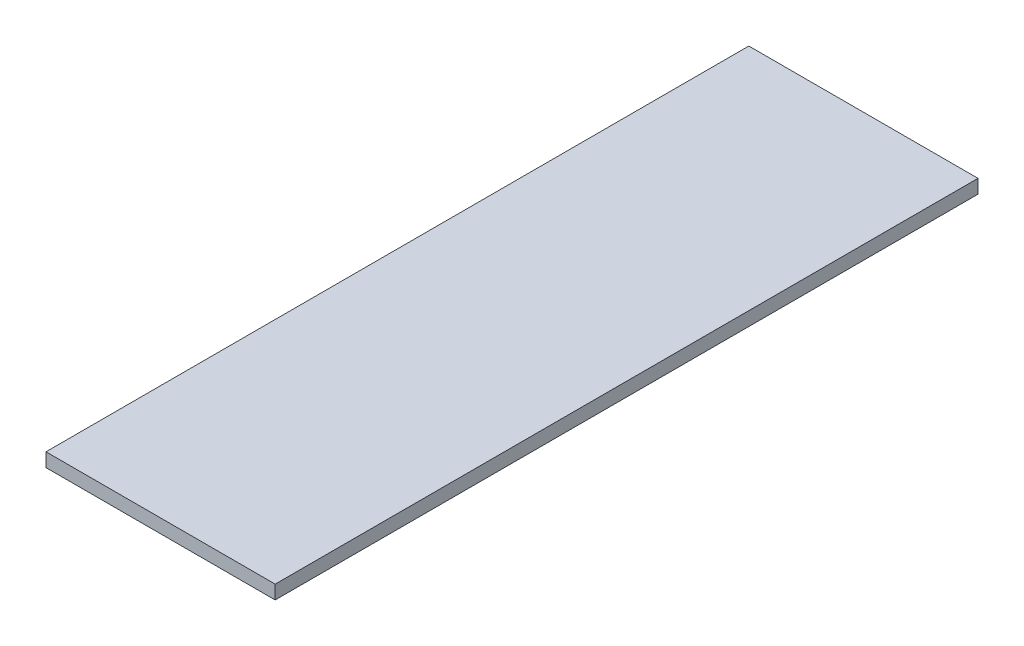
from build123d import *

# Parameters (mm, degrees)
SKETCH_1_W      = 300
SKETCH_1_H      = 920
EXTRUDE_1_DEPTH = 18


with BuildPart() as part:
    # Эскиз1 → Бобышка-Вытянуть1 (new body)
    with BuildSketch(Plane(origin=(0, 0, 0), x_dir=(1, 0, 0), z_dir=(0, 1, 0))):
        Rectangle(SKETCH_1_W, SKETCH_1_H)
    extrude(amount=EXTRUDE_1_DEPTH)


solid = part.part
